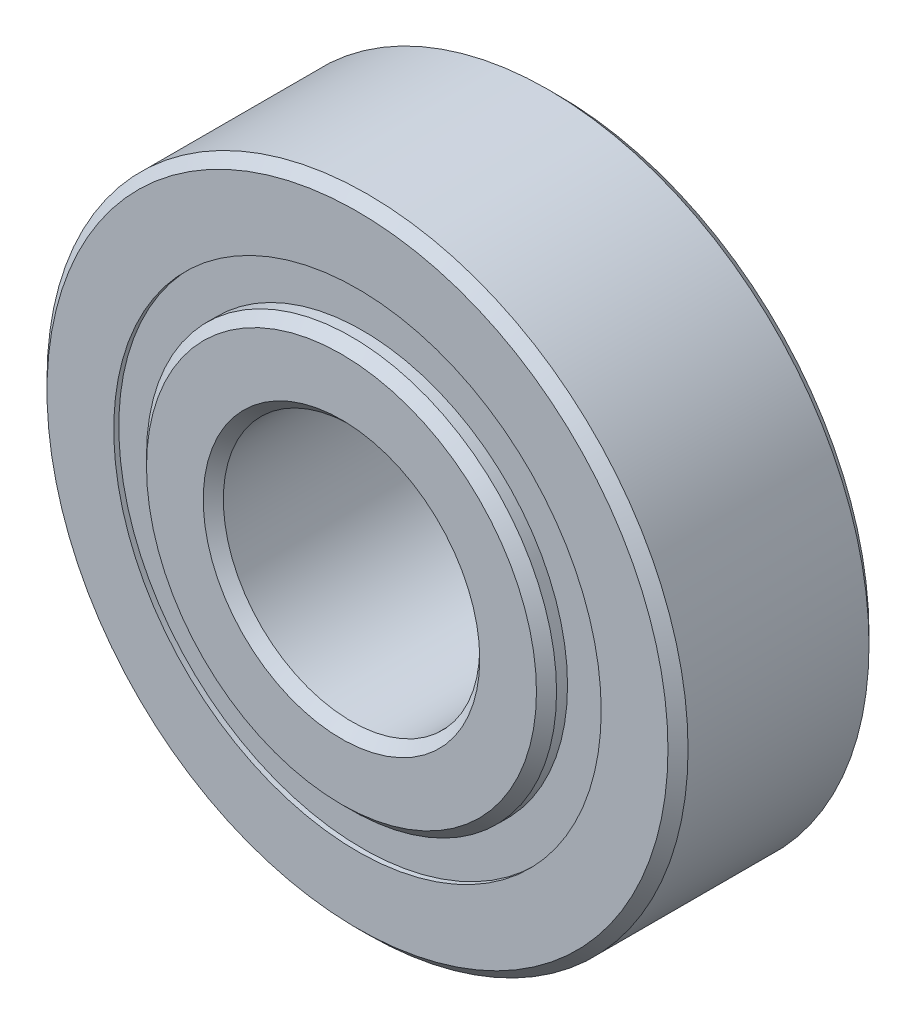
from build123d import *

# Parameters (mm, degrees)
CIRPATTERN1_COUNT = 12
SKETCH5_W         = 1.15919535
SKETCH5_H         = 0.957942858


with BuildPart() as part:
    # Sketch1 → Revolve1 (revolve)
    with BuildSketch(Plane(origin=(0, 0, 0), x_dir=(0, 0, -1), z_dir=(1, 0, 0))):
        with BuildLine():
            Line((2.24028, 7.9375), (-2.24028, 7.9375))
            Line((-2.24028, 7.9375), (-2.4892, 7.68858))
            Line((-2.4892, 7.68858), (-2.4892, 6.035221429))
            Line((-2.4892, 6.035221429), (-1.106311111, 6.035221429))
            ThreePointArc((-1.106311111, 6.035221429), (0, 6.76179465), (1.106311111, 6.035221429))
            Line((1.106311111, 6.035221429), (2.4892, 6.035221429))
            Line((2.4892, 6.035221429), (2.4892, 7.68858))
            Line((2.4892, 7.68858), (2.24028, 7.9375))
        make_face()
    revolve(axis=Axis((0, 0, 2.4892), (0, 0, -1)))


with BuildPart() as body_2:
    # Sketch3 → Revolve3 (revolve)
    with BuildSketch(Plane(origin=(0, 0, 0), x_dir=(0, 0, -1), z_dir=(1, 0, 0))):
        with BuildLine():
            Line((-2.88544, 3.42392), (-2.88544, 4.828358571))
            Line((-2.88544, 4.828358571), (-2.63652, 5.077278571))
            Line((-2.63652, 5.077278571), (-1.106311111, 5.077278571))
            ThreePointArc((-1.106311111, 5.077278571), (0, 4.35070535), (1.106311111, 5.077278571))
            Line((1.106311111, 5.077278571), (2.63652, 5.077278571))
            Line((2.63652, 5.077278571), (2.88544, 4.828358571))
            Line((2.88544, 4.828358571), (2.88544, 3.42392))
            Line((2.88544, 3.42392), (2.63652, 3.175))
            Line((2.63652, 3.175), (-2.63652, 3.175))
            Line((-2.63652, 3.175), (-2.88544, 3.42392))
        make_face()
    revolve(axis=Axis((0, 0, 2.4892), (0, 0, -1)))


with BuildPart() as body_3:
    # Sketch4 → Revolve4 (revolve)
    with BuildSketch(Plane(origin=(0, 0, 0), x_dir=(0, 0, -1), z_dir=(1, 0, 0))):
        with BuildLine():
            Line((-1.20554465, 5.55625), (1.20554465, 5.55625))
            ThreePointArc((1.20554465, 5.55625), (0, 6.76179465), (-1.20554465, 5.55625))
        make_face()
    revolve(axis=Axis((0, 5.55625, 1.20554465), (0, 0, -1)))


with BuildPart() as cirpattern1_1:
    # CirPattern1: pattern copy
    add(body_3.part.rotate(Axis((0, 0, -2.4892), (0, 0, 1)), 1 * 360 / CIRPATTERN1_COUNT))


with BuildPart() as cirpattern1_2:
    # CirPattern1: pattern copy
    add(body_3.part.rotate(Axis((0, 0, -2.4892), (0, 0, 1)), 2 * 360 / CIRPATTERN1_COUNT))


with BuildPart() as cirpattern1_3:
    # CirPattern1: pattern copy
    add(body_3.part.rotate(Axis((0, 0, -2.4892), (0, 0, 1)), 3 * 360 / CIRPATTERN1_COUNT))


with BuildPart() as cirpattern1_4:
    # CirPattern1: pattern copy
    add(body_3.part.rotate(Axis((0, 0, -2.4892), (0, 0, 1)), 4 * 360 / CIRPATTERN1_COUNT))


with BuildPart() as cirpattern1_5:
    # CirPattern1: pattern copy
    add(body_3.part.rotate(Axis((0, 0, -2.4892), (0, 0, 1)), 5 * 360 / CIRPATTERN1_COUNT))


with BuildPart() as cirpattern1_6:
    # CirPattern1: pattern copy
    add(body_3.part.rotate(Axis((0, 0, -2.4892), (0, 0, 1)), 6 * 360 / CIRPATTERN1_COUNT))


with BuildPart() as cirpattern1_7:
    # CirPattern1: pattern copy
    add(body_3.part.rotate(Axis((0, 0, -2.4892), (0, 0, 1)), 7 * 360 / CIRPATTERN1_COUNT))


with BuildPart() as cirpattern1_8:
    # CirPattern1: pattern copy
    add(body_3.part.rotate(Axis((0, 0, -2.4892), (0, 0, 1)), 8 * 360 / CIRPATTERN1_COUNT))


with BuildPart() as cirpattern1_9:
    # CirPattern1: pattern copy
    add(body_3.part.rotate(Axis((0, 0, -2.4892), (0, 0, 1)), 9 * 360 / CIRPATTERN1_COUNT))


with BuildPart() as cirpattern1_10:
    # CirPattern1: pattern copy
    add(body_3.part.rotate(Axis((0, 0, -2.4892), (0, 0, 1)), 10 * 360 / CIRPATTERN1_COUNT))


with BuildPart() as cirpattern1_11:
    # CirPattern1: pattern copy
    add(body_3.part.rotate(Axis((0, 0, -2.4892), (0, 0, 1)), 11 * 360 / CIRPATTERN1_COUNT))


with BuildPart() as body_15:
    # Sketch5 → Revolve5 (revolve)
    with BuildSketch(Plane(origin=(0, 0, 0), x_dir=(0, 0, -1), z_dir=(1, 0, 0))):
        with Locations((-1.785142325, 5.55625)):
            Rectangle(SKETCH5_W, SKETCH5_H)
        with Locations((1.785142325, 5.55625)):
            Rectangle(SKETCH5_W, SKETCH5_H)
    revolve(axis=Axis((0, 0, 2.4892), (0, 0, -1)))


solid = Compound([part.part, body_2.part, body_3.part, cirpattern1_1.part, cirpattern1_2.part, cirpattern1_3.part, cirpattern1_4.part, cirpattern1_5.part, cirpattern1_6.part, cirpattern1_7.part, cirpattern1_8.part, cirpattern1_9.part, cirpattern1_10.part, cirpattern1_11.part, body_15.part])
